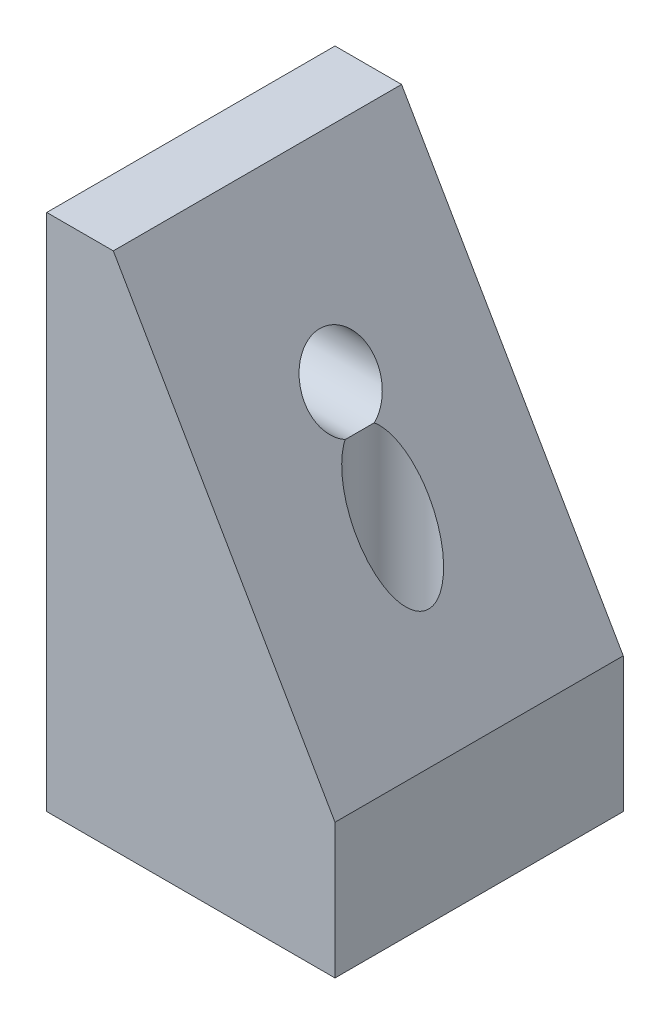
from build123d import *

# Parameters (mm, degrees)
EXTRUDE_1_DEPTH             = 10
HOLE_WIZARD_M31_D           = 2.5
HOLE_WIZARD_M31_CSINK_D     = 3.2
HOLE_WIZARD_M31_CSINK_ANGLE = 110
HOLE_WIZARD_M32_D           = 2.5
HOLE_WIZARD_M32_CSINK_D     = 3.3
HOLE_WIZARD_M32_CSINK_ANGLE = 110


with BuildPart() as part:
    # Эскиз1 → Бобышка-Вытянуть1 (new body)
    with BuildSketch(Plane.XY):
        Polygon((0, 0), (0, 18), (2.309401077, 18), (10, 4.679491924), (10, 0), align=None)
    extrude(amount=EXTRUDE_1_DEPTH)

    # Отверстие обработанное метчиком M31 (through all)
    with Locations(Plane.ZY):
        with Locations((5, 13)):
            CounterSinkHole(HOLE_WIZARD_M31_D / 2, HOLE_WIZARD_M31_CSINK_D / 2, counter_sink_angle=HOLE_WIZARD_M31_CSINK_ANGLE)

    # Отверстие обработанное метчиком M32 (through all)
    with Locations(Plane.XZ):
        with Locations((7, 5)):
            CounterSinkHole(HOLE_WIZARD_M32_D / 2, HOLE_WIZARD_M32_CSINK_D / 2, counter_sink_angle=HOLE_WIZARD_M32_CSINK_ANGLE)


solid = part.part
